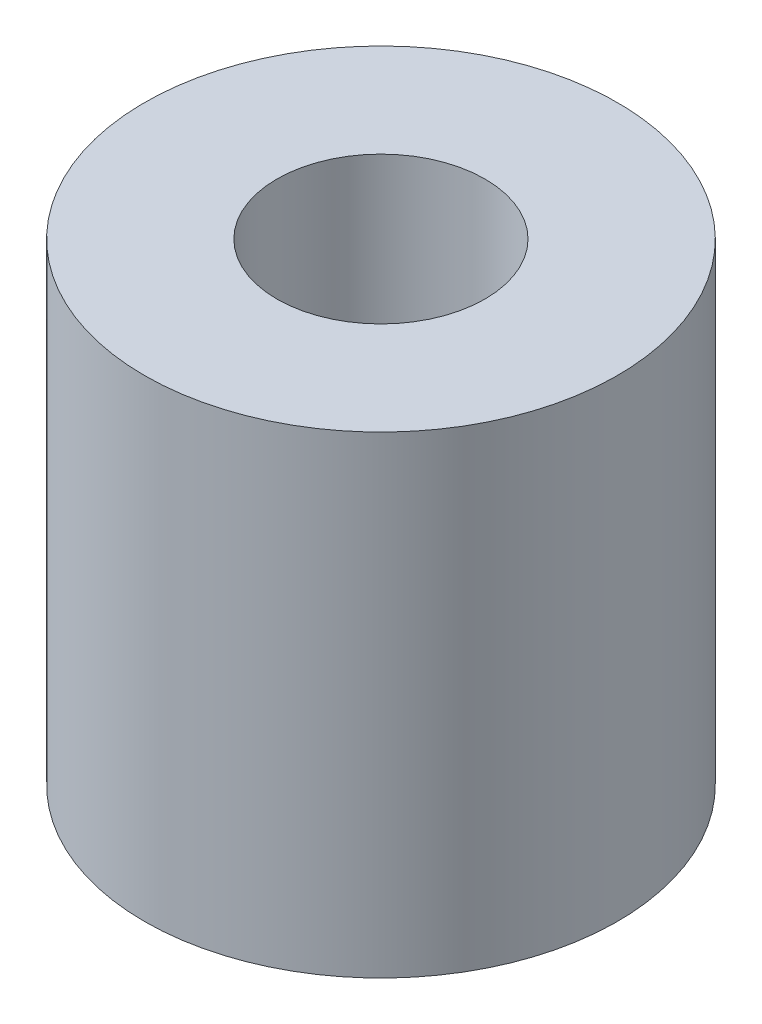
from build123d import *

# Parameters (mm, degrees)
SKETCH1_R           = 2.5
SKETCH1_R_2         = 1.1
BOSS_EXTRUDE1_DEPTH = 5


with BuildPart() as part:
    # Sketch1 → Boss-Extrude1 (new body)
    with BuildSketch(Plane(origin=(0, 0, 0), x_dir=(1, 0, 0), z_dir=(0, 1, 0))):
        Circle(SKETCH1_R)
        Circle(SKETCH1_R_2, mode=Mode.SUBTRACT)
    extrude(amount=BOSS_EXTRUDE1_DEPTH)


solid = part.part
